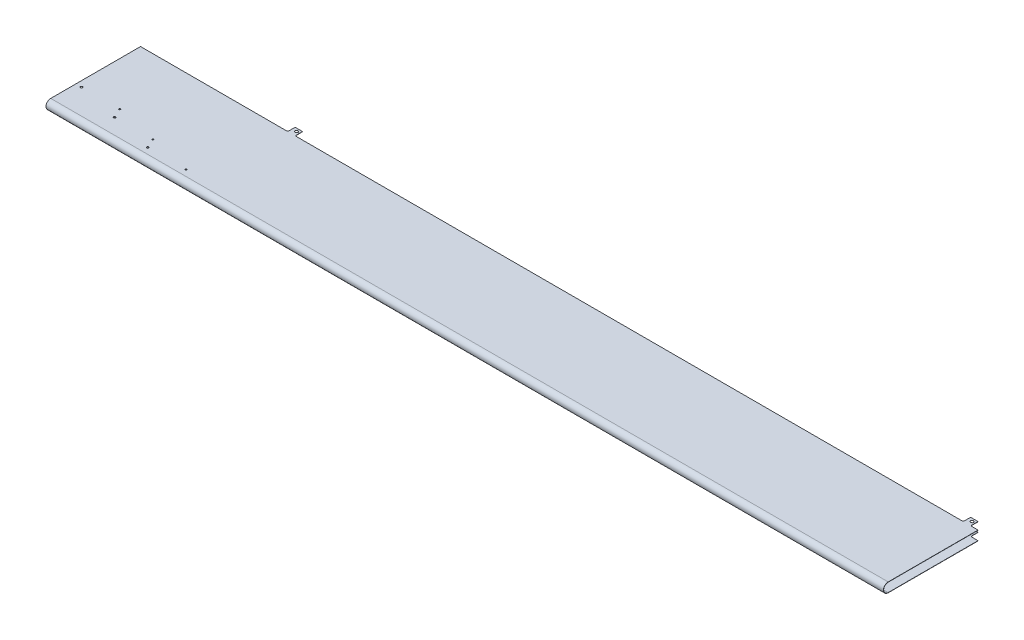
from build123d import *

# Parameters (mm, degrees)
BOSS_EXTRUDE1_DEPTH      = 5
BOSS_EXTRUDE1_DEPTH_BACK = 563.8
CUT_EXTRUDE1_DEPTH       = 7.42512
BOSS_EXTRUDE2_DEPTH      = 91.3
SKETCH4_R                = 0.69
SKETCH4_R_2              = 0.51
CUT_EXTRUDE2_DEPTH       = 2
SKETCH5_R                = 1
CUT_EXTRUDE3_DEPTH       = 7.42512


with BuildPart() as part:
    # Sketch1 → Boss-Extrude1 (new body, two sides)
    with BuildSketch(Plane(origin=(0, 0, 0), x_dir=(0, 0, -1), z_dir=(1, 0, 0))) as boss_extrude1_sk:
        with BuildLine():
            Line((0, 0), (-61, 0))
            ThreePointArc((-61, 0), (-64.21256, -3.21256), (-61, -6.42512))
            Line((-61, -6.42512), (0, -6.42512))
            Line((0, -6.42512), (5, -6.42512))
            Line((5, -6.42512), (5, -6.26256))
            Line((5, -6.26256), (-61, -6.26256))
            ThreePointArc((-61, -6.26256), (-64.05, -3.21256), (-61, -0.16256))
            Line((-61, -0.16256), (5, -0.16256))
            Line((5, -0.16256), (5, 0))
            Line((5, 0), (0, 0))
        make_face()
    extrude(amount=BOSS_EXTRUDE1_DEPTH)
    extrude(boss_extrude1_sk.sketch, amount=-BOSS_EXTRUDE1_DEPTH_BACK)

    # Sketch2 → Cut-Extrude1 (cut, through all)
    with BuildSketch(Plane(origin=(0, 0, 0), x_dir=(1, 0, 0), z_dir=(0, 1, 0))):
        with BuildLine():
            Line((5, 0), (1, 0))
            ThreePointArc((1, 0), (0.292893219, 0.292893219), (0, 1))
            Line((0, 1), (0, 5))
            Line((0, 5), (-5, 5))
            Line((-5, 5), (-5, 1))
            ThreePointArc((-5, 1), (-5.292893219, 0.292893219), (-6, 0))
            Line((-6, 0), (-457.8, 0))
            ThreePointArc((-457.8, 0), (-458.507106781, 0.292893219), (-458.8, 1))
            Line((-458.8, 1), (-458.8, 5))
            Line((-458.8, 5), (-463.8, 5))
            Line((-463.8, 5), (-463.8, 1))
            ThreePointArc((-463.8, 1), (-464.092893219, 0.292893219), (-464.8, 0))
            Line((-464.8, 0), (-563.8, 0))
            Line((-563.8, 0), (-563.8, 10))
            Line((-563.8, 10), (5, 10))
            Line((5, 10), (5, 0))
        make_face()
    extrude(amount=-CUT_EXTRUDE1_DEPTH, mode=Mode.SUBTRACT)

    # Sketch3 → Boss-Extrude2 (add)
    with BuildSketch(Plane.ZY.offset(563.8)):
        with BuildLine():
            Line((61, -0.23114), (0, -0.23114))
            Line((0, -0.23114), (0, 0))
            Line((0, 0), (61, 0))
            ThreePointArc((61, 0), (64.21256, -3.21256), (61, -6.42512))
            Line((61, -6.42512), (0, -6.42512))
            Line((0, -6.42512), (0, -6.19398))
            Line((0, -6.19398), (61, -6.19398))
            ThreePointArc((61, -6.19398), (63.98142, -3.21256), (61, -0.23114))
        make_face()
    extrude(amount=-BOSS_EXTRUDE2_DEPTH)

    # Sketch4 → Cut-Extrude2 (cut)
    with BuildSketch(Plane(origin=(0, 0, 0), x_dir=(1, 0, 0), z_dir=(0, 1, 0))):
        with Locations(Location((-560.001, -43.918, 0), (0, 0, 270))):  # turned: the seam where the file's is
            Circle(SKETCH4_R)
        with Locations(Location((-534.001, -43.918, 0), (0, 0, 270))):  # turned: the seam where the file's is
            Circle(SKETCH4_R_2)
        with Locations(Location((-531.001, -50.418, 0), (0, 0, 270))):  # turned: the seam where the file's is
            Circle(SKETCH4_R)
        with Locations(Location((-505.001, -50.418, 0), (0, 0, 270))):  # turned: the seam where the file's is
            Circle(SKETCH4_R_2)
        with Locations(Location((-502.001, -56.918, 0), (0, 0, 270))):  # turned: the seam where the file's is
            Circle(SKETCH4_R)
        with Locations(Location((-476.001, -56.918, 0), (0, 0, 270))):  # turned: the seam where the file's is
            Circle(SKETCH4_R_2)
    extrude(amount=-CUT_EXTRUDE2_DEPTH, mode=Mode.SUBTRACT)

    # Sketch5 → Cut-Extrude3 (cut, through all)
    with BuildSketch(Plane(origin=(0, 0, 0), x_dir=(1, 0, 0), z_dir=(0, 1, 0))):
        with Locations(Location((-460.8, 2.99, 0), (0, 0, 270))):  # turned: the seam where the file's is
            Circle(SKETCH5_R)
        with Locations(Location((-2, 2.99, 0), (0, 0, 270))):  # turned: the seam where the file's is
            Circle(SKETCH5_R)
    extrude(amount=-CUT_EXTRUDE3_DEPTH, mode=Mode.SUBTRACT)


solid = part.part
